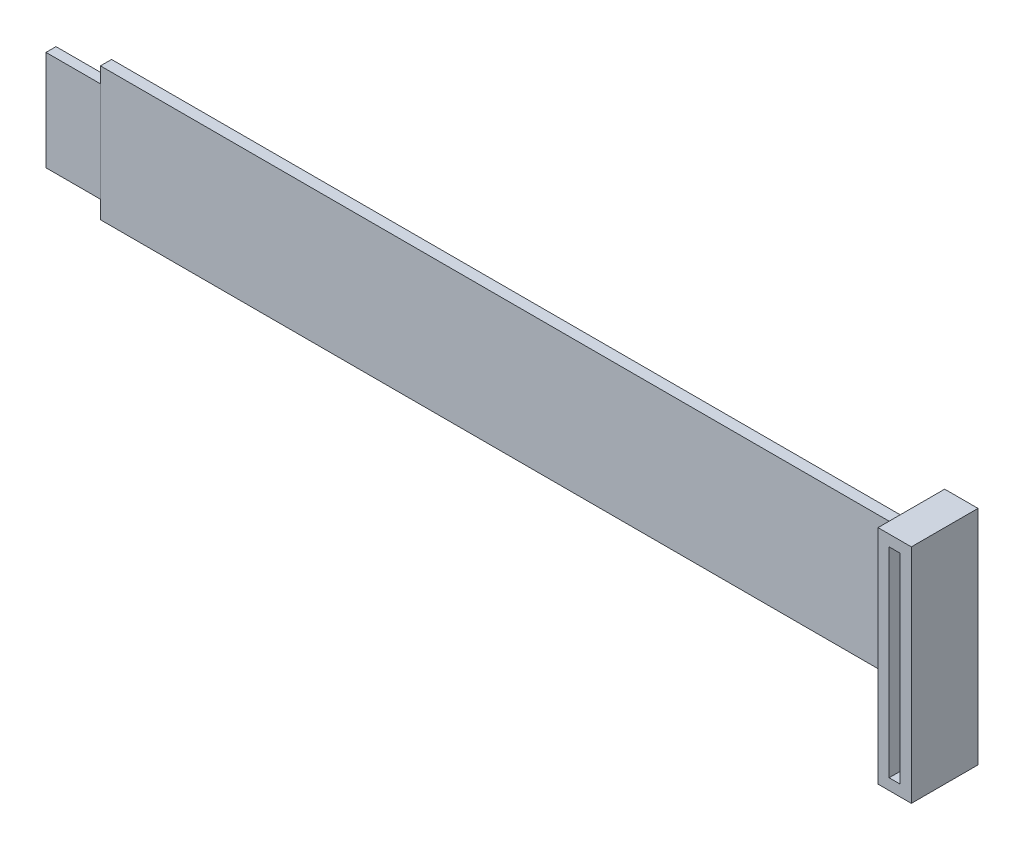
from build123d import *

# Parameters (mm, degrees)
SALIENTE_EXTRUIR1_DEPTH = 2
CROQUIS2_W              = 2
CROQUIS2_H              = 36
SALIENTE_EXTRUIR2_DEPTH = 2
CROQUIS2_2_W            = 2
CROQUIS2_2_H            = 36
SALIENTE_EXTRUIR3_DEPTH = 10
CROQUIS3_W              = 10
CROQUIS3_H              = 1
CORTAR_EXTRUIR1_DEPTH   = 2
CROQUIS4_W              = 10
CROQUIS4_H              = 0.2
CORTAR_EXTRUIR2_DEPTH   = 18


with BuildPart() as part:
    # Croquis1 → Saliente-Extruir1 (new body)
    with BuildSketch(Plane.XY):
        Polygon((-8.516541248, 1.295896328), (1.483458752, 1.295896328), (1.483458752, 3.295896328), (151.483458752, 3.295896328), (151.483458752, -20.704103672), (1.483458752, -20.704103672), (1.483458752, -18.704103672), (-8.516541248, -18.704103672), align=None)
    extrude(amount=SALIENTE_EXTRUIR1_DEPTH)

    # Croquis2 → Saliente-Extruir2 (add)
    with BuildSketch(Plane.XY.offset(2)):
        Polygon((151.483458752, 3.295896328), (151.483458752, 11.295896328), (157.483458752, 11.295896328), (157.483458752, -28.704103672), (151.483458752, -28.704103672), align=None)
        with Locations((154.483458752, -8.704103672)):
            Rectangle(CROQUIS2_W, CROQUIS2_H, mode=Mode.SUBTRACT)
    extrude(amount=-SALIENTE_EXTRUIR2_DEPTH)

    # Croquis2_2 → Saliente-Extruir3 (add)
    with BuildSketch(Plane.XY.offset(2)):
        Polygon((151.483458752, 3.295896328), (151.483458752, 11.295896328), (157.483458752, 11.295896328), (157.483458752, -28.704103672), (151.483458752, -28.704103672), align=None)
        with Locations((154.483458752, -8.704103672)):
            Rectangle(CROQUIS2_2_W, CROQUIS2_2_H, mode=Mode.SUBTRACT)
    extrude(amount=SALIENTE_EXTRUIR3_DEPTH)

    # Croquis3 → Cortar-Extruir1 (cut)
    with BuildSketch(Plane.XY.offset(2)):
        with Locations((-3.516541248, 0.795896328)):
            Rectangle(CROQUIS3_W, CROQUIS3_H)
        with Locations((-3.516541248, -18.204103672)):
            Rectangle(CROQUIS3_W, CROQUIS3_H)
    extrude(amount=-CORTAR_EXTRUIR1_DEPTH, mode=Mode.SUBTRACT)

    # Croquis4 → Cortar-Extruir2 (cut)
    with BuildSketch(Plane.XZ.offset(17.704103672)):
        with Locations((-3.516541248, 1.9)):
            Rectangle(CROQUIS4_W, CROQUIS4_H)
    extrude(amount=-CORTAR_EXTRUIR2_DEPTH, mode=Mode.SUBTRACT)


solid = part.part
